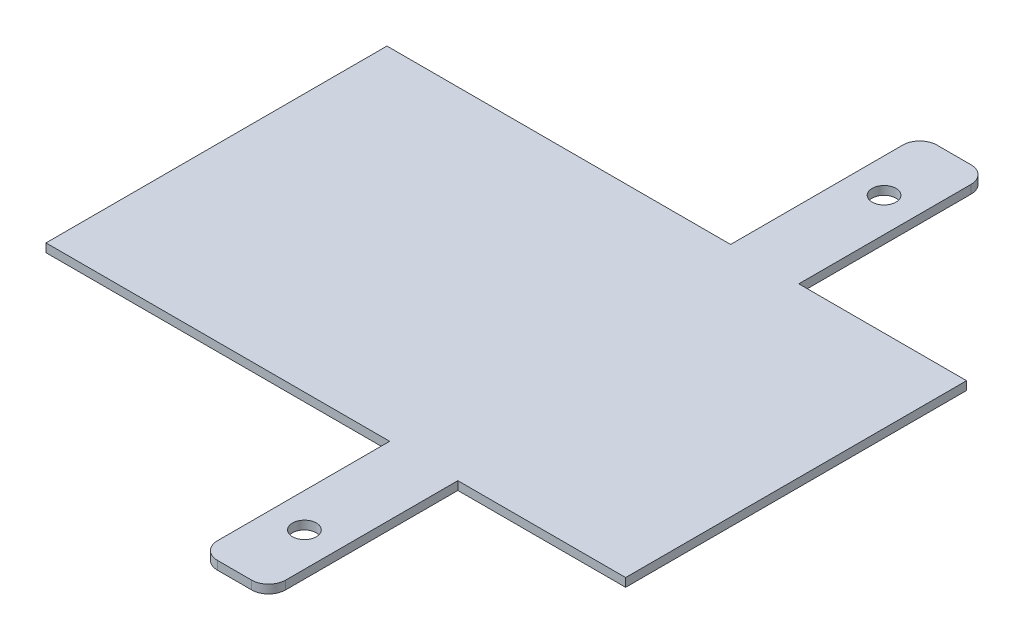
from build123d import *

# Parameters (mm, degrees)
SKETCH1_R           = 7
BOSS_EXTRUDE1_DEPTH = 5


with BuildPart() as part:
    # Sketch1 → Boss-Extrude1 (new body)
    with BuildSketch(Plane(origin=(0, 0, 0), x_dir=(1, 0, 0), z_dir=(0, 1, 0))):
        with BuildLine():
            Line((-449.708642176, 422.631578947), (-351.296475424, 422.631578947))
            Line((-351.296475424, 422.631578947), (-351.296475424, 222.631578947))
            Line((-351.296475424, 222.631578947), (-449.708642176, 222.631578947))
            Line((-449.708642176, 222.631578947), (-449.708642176, 121.631578947))
            ThreePointArc((-449.708642176, 121.631578947), (-452.637574364, 114.560511136), (-459.708642176, 111.631578947))
            Line((-459.708642176, 111.631578947), (-479.708642176, 111.631578947))
            ThreePointArc((-479.708642176, 111.631578947), (-486.779709988, 114.560511136), (-489.708642176, 121.631578947))
            Line((-489.708642176, 121.631578947), (-489.708642176, 222.631578947))
            Line((-489.708642176, 222.631578947), (-691.296475424, 222.631578947))
            Line((-691.296475424, 222.631578947), (-691.296475424, 422.631578947))
            Line((-691.296475424, 422.631578947), (-489.708642176, 422.631578947))
            Line((-489.708642176, 422.631578947), (-489.708642176, 523.631578947))
            ThreePointArc((-489.708642176, 523.631578947), (-486.779709988, 530.702646759), (-479.708642176, 533.631578947))
            Line((-479.708642176, 533.631578947), (-459.708642176, 533.631578947))
            ThreePointArc((-459.708642176, 533.631578947), (-452.637574364, 530.702646759), (-449.708642176, 523.631578947))
            Line((-449.708642176, 523.631578947), (-449.708642176, 422.631578947))
        make_face()
        with Locations((-469.708642176, 492.631578947)):
            Circle(SKETCH1_R, mode=Mode.SUBTRACT)
        with Locations((-469.708642176, 152.631578947)):
            Circle(SKETCH1_R, mode=Mode.SUBTRACT)
    extrude(amount=BOSS_EXTRUDE1_DEPTH)


solid = part.part
